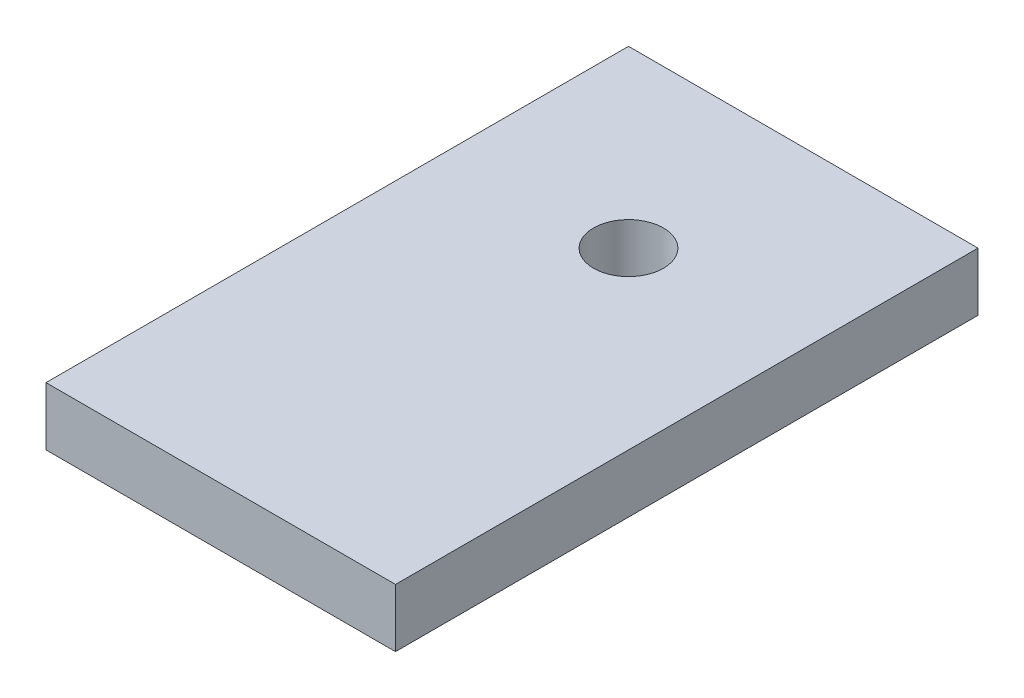
from build123d import *

# Parameters (mm, degrees)
SKETCH1_W           = 30
SKETCH1_H           = 50
BOSS_EXTRUDE1_DEPTH = 5
SKETCH2_R           = 3
CUT_EXTRUDE1_DEPTH  = 5


with BuildPart() as part:
    # Sketch1 → Boss-Extrude1 (new body)
    with BuildSketch(Plane(origin=(0, 0, 0), x_dir=(1, 0, 0), z_dir=(0, 1, 0))):
        Rectangle(SKETCH1_W, SKETCH1_H)
    extrude(amount=BOSS_EXTRUDE1_DEPTH)

    # Sketch2 → Cut-Extrude1 (cut)
    with BuildSketch(Plane(origin=(0, 5, 0), x_dir=(1, 0, 0), z_dir=(0, 1, 0))):
        with Locations((0, 10)):
            Circle(SKETCH2_R)
    extrude(amount=-CUT_EXTRUDE1_DEPTH, mode=Mode.SUBTRACT)


solid = part.part
